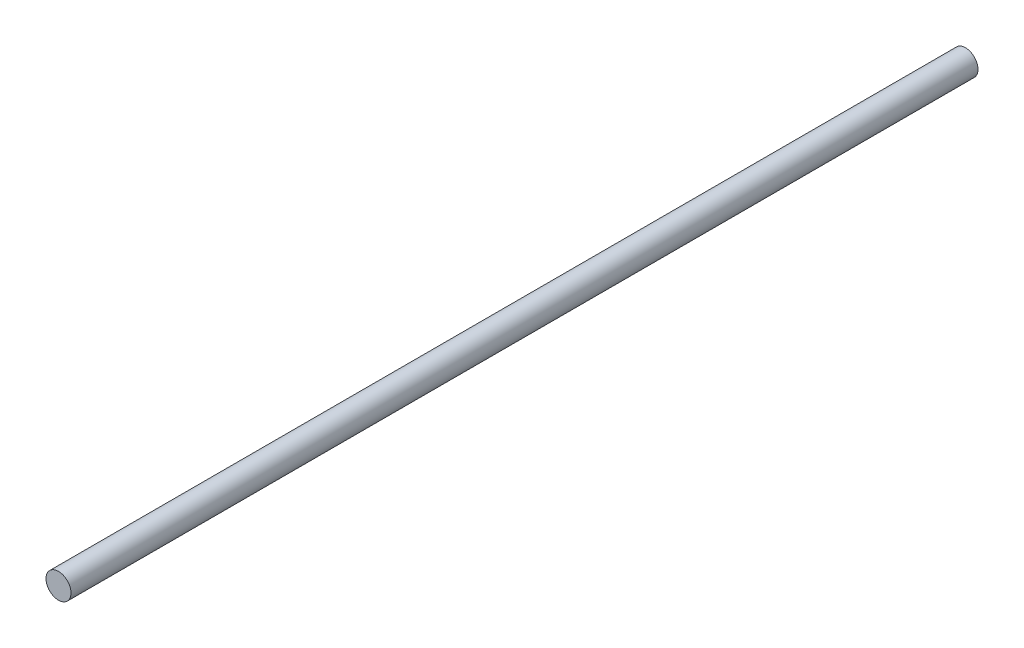
from build123d import *

# Parameters (mm, degrees)
SKETCH1_R           = 4
BOSS_EXTRUDE1_DEPTH = 290


with BuildPart() as part:
    # Sketch1 → Boss-Extrude1 (new body)
    with BuildSketch(Plane.XY):
        Circle(SKETCH1_R)
    extrude(amount=-BOSS_EXTRUDE1_DEPTH)


solid = part.part
